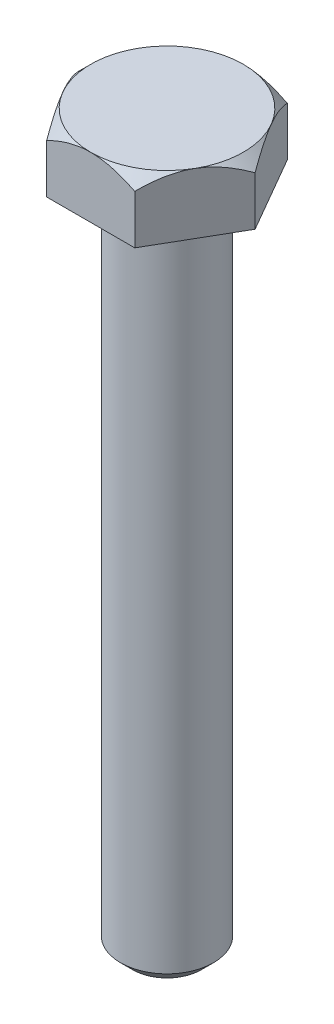
from build123d import *

# Parameters (mm, degrees)
EXTRUDE_1_DEPTH     = 5
SKETCH_8_OUTSIDE_W  = 22.464
SKETCH_8_OUTSIDE_H  = 20.522
SKETCH_8_OUTSIDE_R  = 6.278684177
CUT_EXTRUDE_1_DEPTH = 1
CUT_EXTRUDE_1_DRAFT = -45
SKETCH_9_R          = 3.825
BOLT_LENGTH_DEPTH   = 55
FILLET_1_R          = 1
CHAMFER_1_SIZE      = 1


with BuildPart() as part:
    # Эскиз6 → Бобышка-Вытянуть1 (new body)
    with BuildSketch(Plane(origin=(0, 0, 0), x_dir=(1, 0, 0), z_dir=(0, 1, 0))):
        Polygon((7.25, 0), (3.625, 6.278684177), (-3.625, 6.278684177), (-7.25, 0), (-3.625, -6.278684177), (3.625, -6.278684177), align=None)
    extrude(amount=EXTRUDE_1_DEPTH)


with BuildPart() as cut_extrude_1_tool:
    # Эскиз8 outside → Вырез-Вытянуть1 (with draft: the straight prism first)
    with BuildSketch(Plane(origin=(0, 5, 0), x_dir=(1, 0, 0), z_dir=(0, 1, 0))):
        Rectangle(SKETCH_8_OUTSIDE_W, SKETCH_8_OUTSIDE_H)
        Circle(SKETCH_8_OUTSIDE_R, mode=Mode.SUBTRACT)
    extrude(amount=-CUT_EXTRUDE_1_DEPTH)
    # Вырез-Вытянуть1: the draft: its side faces are tilted about the plane it starts from
    cut_extrude_1_sides = [cut_extrude_1_tool.faces().sort_by_distance(p)[0] for p in [
        (0, 4.5, 10.261),
        (11.232, 4.5, 0),
        (0, 4.5, -10.261),
        (-11.232, 4.5, 0),
        (-6.278684177, 4.5, 0),
    ]]
    draft(cut_extrude_1_sides, Plane(origin=(0, 5, 0), x_dir=(1, 0, 0), z_dir=(0, 1, 0)), CUT_EXTRUDE_1_DRAFT)


with BuildPart() as part_1:
    add(part.part)

    # Вырез-Вытянуть1: cut by cut_extrude_1_tool
    add(cut_extrude_1_tool.part, mode=Mode.SUBTRACT)

    # Эскиз9 → bolt length (add)
    with BuildSketch(Plane.XZ):
        with Locations(Location((0, 0, 0), (0, 0, 90))):  # turned: the seam where the file's is
            Circle(SKETCH_9_R)
    extrude(amount=BOLT_LENGTH_DEPTH)

    # Скругление1
    fillet_1_edges = [part_1.edges().sort_by_distance(p)[0] for p in [
        (0, 0, -3.825),
    ]]
    fillet(fillet_1_edges, radius=FILLET_1_R)

    # Фаска1
    chamfer_1_edges = [part_1.edges().sort_by_distance(p)[0] for p in [
        (0, -55, -3.825),
    ]]
    chamfer(chamfer_1_edges, length=CHAMFER_1_SIZE)


solid = part_1.part
